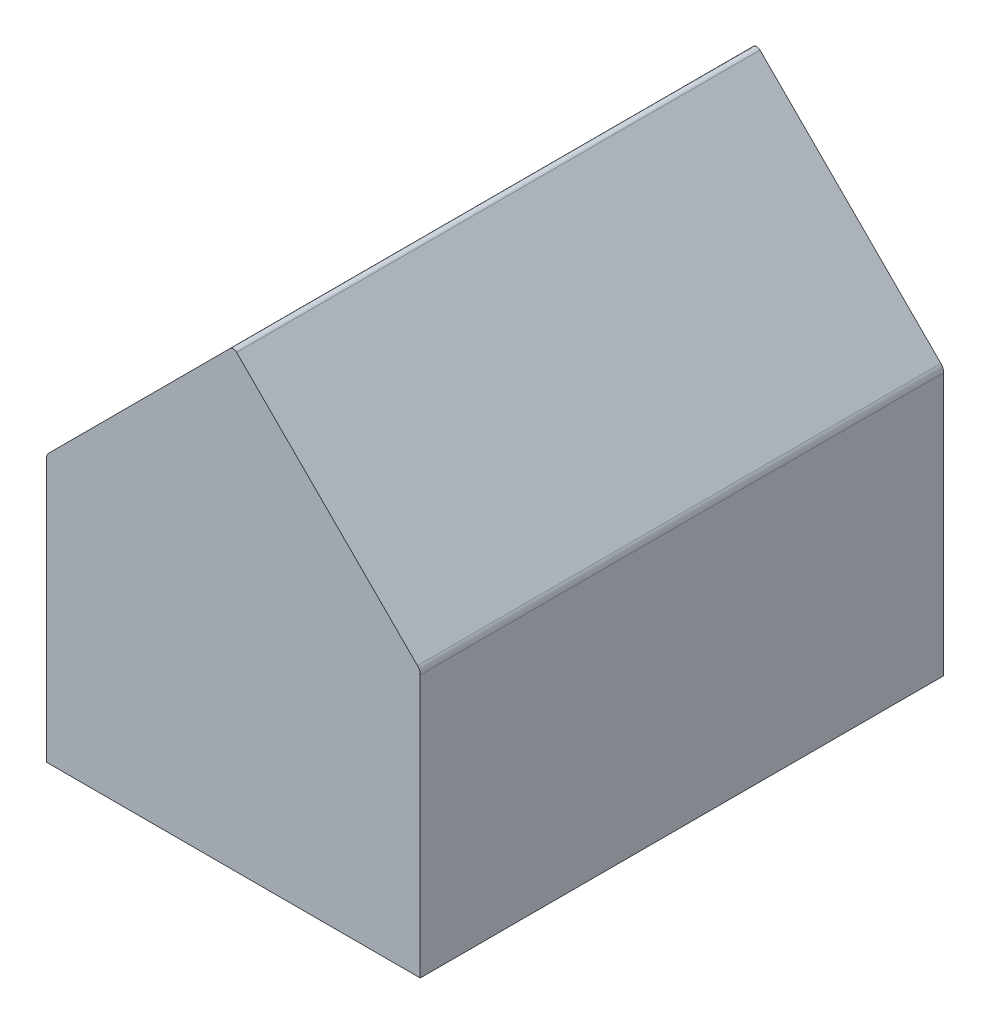
from build123d import *

# Parameters (mm, degrees)
SKETCH1_W           = 10.16
SKETCH1_H           = 7.239
BOSS_EXTRUDE1_DEPTH = 7.112
FILLET2_R           = 0.254
FILLET3_R           = 0.127


with BuildPart() as part:
    # Sketch1 → Boss-Extrude1 (new body, symmetric)
    with BuildSketch(Plane.XY):
        Polygon((0, 8.6995), (5.08, 3.6195), (-5.08, 3.6195), align=None)
        Rectangle(SKETCH1_W, SKETCH1_H)
    extrude(amount=BOSS_EXTRUDE1_DEPTH, both=True)

    # Fillet2
    fillet2_edges = [part.edges().sort_by_distance(p)[0] for p in [
        (5.08, 3.6195, 0),
        (-5.08, 3.6195, 0),
    ]]
    fillet(fillet2_edges, radius=FILLET2_R)

    # Fillet3
    fillet3_edges = [part.edges().sort_by_distance(p)[0] for p in [
        (0, 8.6995, 0),
    ]]
    fillet(fillet3_edges, radius=FILLET3_R)


solid = part.part
